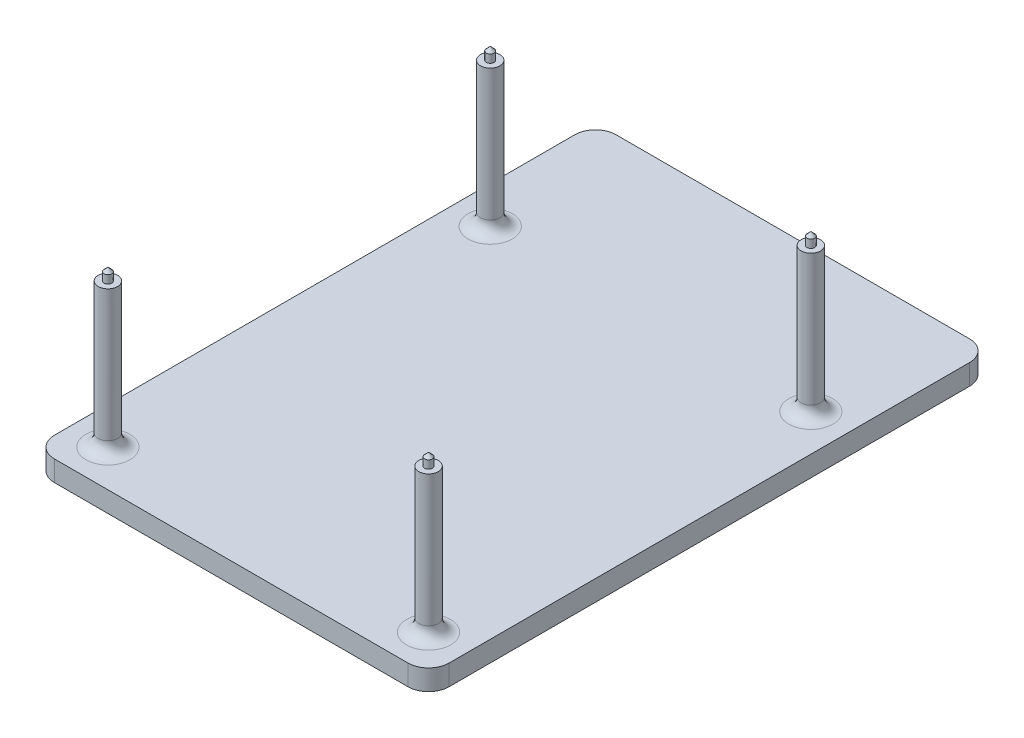
from build123d import *

# Parameters (mm, degrees)
SKETCH1_W           = 121.92
SKETCH1_H           = 173.482
BOSS_EXTRUDE1_DEPTH = 6.35
SKETCH2_R           = 3
BOSS_EXTRUDE2_DEPTH = 44.45
FILLET1_R           = 6.35
FILLET2_R           = 3.81


with BuildPart() as part:
    # Sketch1 → Boss-Extrude1 (new body)
    with BuildSketch(Plane(origin=(0, 0, 0), x_dir=(1, 0, 0), z_dir=(0, 1, 0))):
        with Locations((54.61, 80.391)):
            Rectangle(SKETCH1_W, SKETCH1_H)
    extrude(amount=BOSS_EXTRUDE1_DEPTH)

    # Sketch2 → Boss-Extrude2 (add)
    with BuildSketch(Plane(origin=(0, 6.35, 0), x_dir=(1, 0, 0), z_dir=(0, 1, 0))):
        with Locations((104.14, 5.08)):
            Circle(SKETCH2_R)
        with Locations((104.14, 123.19)):
            Circle(SKETCH2_R)
        with Locations((5.08, 123.19)):
            Circle(SKETCH2_R)
        with Locations((5.08, 5.08)):
            Circle(SKETCH2_R)
    extrude(amount=BOSS_EXTRUDE2_DEPTH)

    # Fillet1
    fillet1_edges = [part.edges().sort_by_distance(p)[0] for p in [
        (115.57, 3.175, 6.35),
        (-6.35, 3.175, 6.35),
        (115.57, 3.175, -167.132),
        (-6.35, 3.175, -167.132),
    ]]
    fillet(fillet1_edges, radius=FILLET1_R)

    # Fillet2
    fillet2_edges = [part.edges().sort_by_distance(p)[0] for p in [
        (101.14, 6.35, -5.08),
        (101.14, 6.35, -123.19),
        (2.08, 6.35, -123.19),
        (2.08, 6.35, -5.08),
    ]]
    fillet(fillet2_edges, radius=FILLET2_R)

    # Sketch3 → Revolve1 (revolve)
    with BuildSketch(Plane.XY.offset(-5.08)):
        Polygon((3.880000114, 50.8), (5.08, 50.8), (5.08, 54.499999886), (3.880000114, 53.3), align=None)
    revolve1 = revolve(axis=Axis((5.08, 50.8, -5.08), (0, -1, 0)))

    # Mirror1: Revolve1 across plane
    add(revolve1.mirror(Plane.XY.offset(-64.135)))

    # Mirror2: Revolve1 across plane
    add(revolve1.mirror(Plane.ZY.offset(-54.61)))

    # Mirror2 copy 1 sketch → Mirror2 copy 1 (revolve)
    with BuildSketch(Plane(origin=(109.22, 0, -123.19), x_dir=(-1, 0, 0), z_dir=(0, 0, -1))):
        Polygon((3.880000114, 50.8), (5.08, 50.8), (5.08, 54.499999886), (3.880000114, 53.3), align=None)
    revolve(axis=Axis((104.14, 50.8, -123.19), (0, -1, 0)))


solid = part.part
